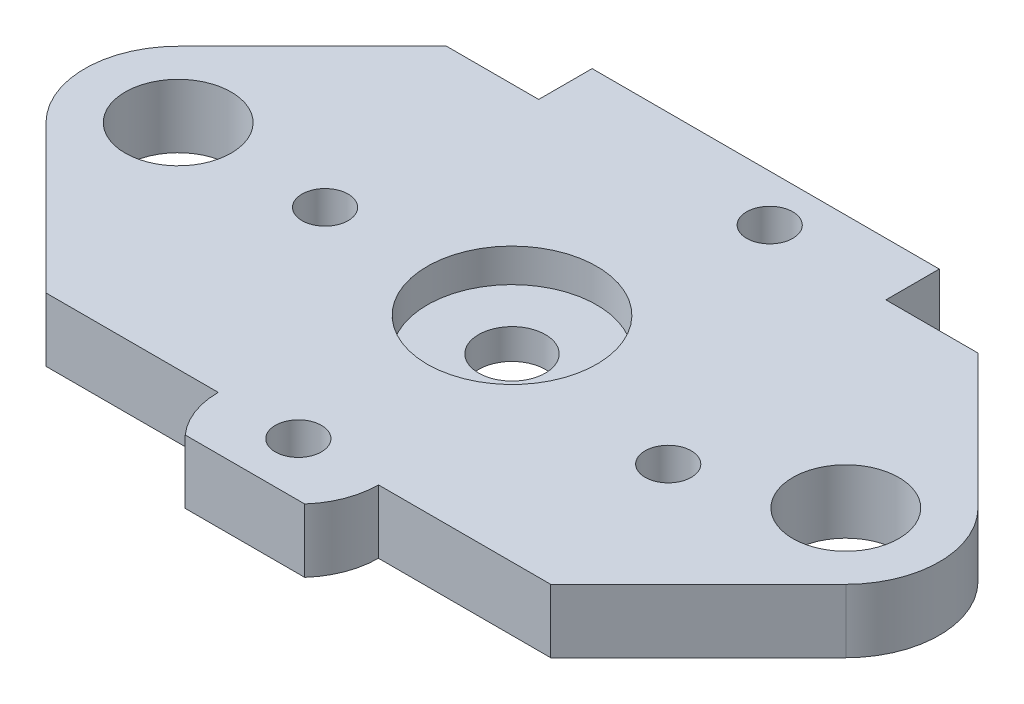
from build123d import *

# Parameters (mm, degrees)
SKETCH1_W             = 65
SKETCH1_H             = 45
BOSS_EXTRUDE1_DEPTH   = 4.7625
SKETCH2_R             = 2.5
CUT_EXTRUDE1_DEPTH    = 5.7625
F_8_32_TAPPED_HOLE1_D = 3.4544
SKETCH6_R             = 3.96875
CUT_EXTRUDE2_DEPTH    = 5.7625
CUT_EXTRUDE3_DEPTH    = 5.7625
SKETCH9_R             = 6.35
CUT_EXTRUDE4_DEPTH    = 2.5


with BuildPart() as part:
    # Sketch1 → Boss-Extrude1 (new body)
    with BuildSketch(Plane(origin=(0, 0, 0), x_dir=(1, 0, 0), z_dir=(0, 1, 0))):
        Rectangle(SKETCH1_W, SKETCH1_H)
    extrude(amount=BOSS_EXTRUDE1_DEPTH)

    # Sketch2 → Cut-Extrude1 (cut, through all)
    with BuildSketch(Plane(origin=(0, 4.7625, 0), x_dir=(1, 0, 0), z_dir=(0, 1, 0))):
        Circle(SKETCH2_R)
    extrude(amount=-CUT_EXTRUDE1_DEPTH, mode=Mode.SUBTRACT)

    # #8-32 Tapped Hole1 (through all)
    with Locations(Plane(origin=(-15.76090252, 4.7625, 28.427239646), x_dir=(-1, 0, 0), z_dir=(0, 1, 0))):
        with Locations((-31.26090252, -24.627239646), (-1.76090252, -28.427239646), (-19.56090252, -43.927239646), (-15.76090252, -12.427239646)):
            Hole(F_8_32_TAPPED_HOLE1_D / 2)

    # Sketch6 → Cut-Extrude2 (cut, through all)
    with BuildSketch(Plane(origin=(0, 4.7625, 0), x_dir=(1, 0, 0), z_dir=(0, 1, 0))):
        with Locations((-25, 0)):
            Circle(SKETCH6_R)
        with Locations((25, 0)):
            Circle(SKETCH6_R)
    extrude(amount=-CUT_EXTRUDE2_DEPTH, mode=Mode.SUBTRACT)

    # Sketch8 → Cut-Extrude3 (cut, through all)
    with BuildSketch(Plane(origin=(0, 4.7625, 0), x_dir=(1, 0, 0), z_dir=(0, 1, 0))):
        with BuildLine():
            Line((6, -16), (18.899494937, -16))
            Line((18.899494937, -16), (29.949747468, -4.949747468))
            ThreePointArc((29.949747468, -4.949747468), (32, 0), (29.949747468, 4.949747468))
            Line((29.949747468, 4.949747468), (19.899494937, 15))
            Line((19.899494937, 15), (13, 15))
            Line((13, 15), (13, 19))
            Line((13, 19), (0, 19))
            Line((0, 19), (0, 22.5))
            Line((0, 22.5), (32.5, 22.5))
            Line((32.5, 22.5), (32.5, -22.5))
            Line((32.5, -22.5), (0, -22.5))
            Line((0, -22.5), (0, -20))
            Line((0, -20), (4.472135955, -20))
            ThreePointArc((4.472135955, -20), (5.605034154, -18.140932539), (6, -16))
        make_face()
    cut_extrude3 = extrude(amount=-CUT_EXTRUDE3_DEPTH, mode=Mode.SUBTRACT)

    # Mirror1: Cut-Extrude3 across plane
    add(cut_extrude3.mirror(Plane(origin=(0, 0, 0), x_dir=(0, 0, 1), z_dir=(1, 0, 0))), mode=Mode.SUBTRACT)

    # Sketch9 → Cut-Extrude4 (cut)
    with BuildSketch(Plane(origin=(0, 4.7625, 0), x_dir=(1, 0, 0), z_dir=(0, 1, 0))):
        Circle(SKETCH9_R)
    extrude(amount=-CUT_EXTRUDE4_DEPTH, mode=Mode.SUBTRACT)


solid = part.part
